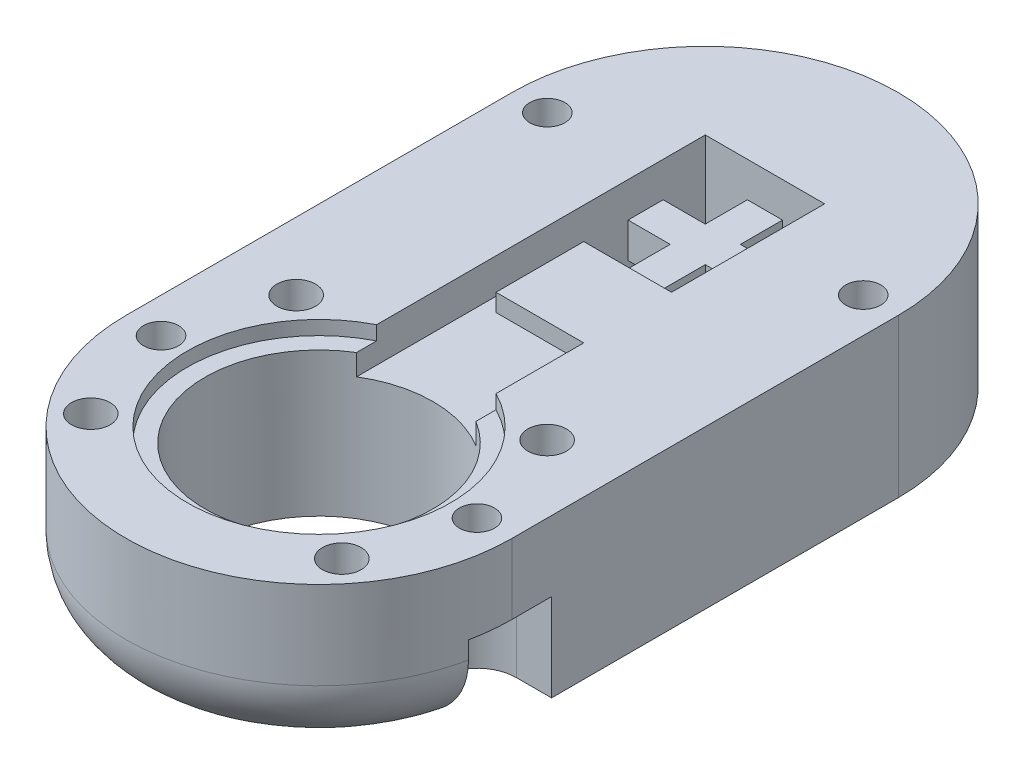
from build123d import *

# Parameters (mm, degrees)
SKETCH1_R           = 6.5
BOSS_EXTRUDE1_DEPTH = 9
SKETCH2_R           = 1.1
CUT_EXTRUDE1_DEPTH  = 3
SKETCH3_R           = 1
CUT_EXTRUDE2_DEPTH  = 20
CUT_EXTRUDE3_DEPTH  = 5
SKETCH6_W           = 6.8
SKETCH6_H           = 6.8
CUT_EXTRUDE4_DEPTH  = 5
SKETCH7_W           = 2.4
SKETCH7_H           = 2.4
CUT_EXTRUDE5_DEPTH  = 5
FILLET2_R           = 4
SKETCH8_R           = 1
CUT_EXTRUDE6_DEPTH  = 20
SKETCH9_R           = 7.5
CUT_EXTRUDE7_DEPTH  = 0.8
SKETCH10_W          = 6.8
SKETCH10_H          = 19.870144406
CUT_EXTRUDE8_DEPTH  = 2
SKETCH11_W          = 5
SKETCH11_H          = 1
BOSS_EXTRUDE2_DEPTH = 5


with BuildPart() as part:
    # Sketch1 → Boss-Extrude1 (new body)
    with BuildSketch(Plane(origin=(0, 0, 0), x_dir=(1, 0, 0), z_dir=(0, 1, 0))):
        with BuildLine():
            Line((-11, 0), (-11, 22.01))
            ThreePointArc((-11, 22.01), (-7.781103525, 29.781103525), (-0.01, 33))
            Line((-0.01, 33), (0.01, 33))
            ThreePointArc((0.01, 33), (7.781103525, 29.781103525), (11, 22.01))
            Line((11, 22.01), (11, 0))
            ThreePointArc((11, 0), (0, -11), (-11, 0))
        make_face()
        Circle(SKETCH1_R, mode=Mode.SUBTRACT)
    extrude(amount=BOSS_EXTRUDE1_DEPTH)

    # Sketch2 → Cut-Extrude1 (cut)
    with BuildSketch(Plane(origin=(0, 9, 0), x_dir=(1, 0, 0), z_dir=(0, 1, 0))):
        with Locations((-7.15, 5.85)):
            Circle(SKETCH2_R)
        with Locations((-7.15, -5.85)):
            Circle(SKETCH2_R)
        with Locations((7.15, -5.85)):
            Circle(SKETCH2_R)
        with Locations((7.15, 5.85)):
            Circle(SKETCH2_R)
    extrude(amount=-CUT_EXTRUDE1_DEPTH, mode=Mode.SUBTRACT)

    # Sketch3 → Cut-Extrude2 (cut)
    with BuildSketch(Plane(origin=(0, 9, 0), x_dir=(1, 0, 0), z_dir=(0, 1, 0))):
        with Locations((-9, 0)):
            Circle(SKETCH3_R)
        with Locations((9, 0)):
            Circle(SKETCH3_R)
    extrude(amount=-CUT_EXTRUDE2_DEPTH, mode=Mode.SUBTRACT)

    # Sketch4 → Cut-Extrude3 (cut)
    with BuildSketch(Plane.XZ):
        with BuildLine():
            Line((-9, 2.25), (-10.767427734, 2.25))
            Line((-10.767427734, 2.25), (-12, 0))
            Line((-12, 0), (-11, -2.25))
            Line((-11, -2.25), (-9, -2.25))
            ThreePointArc((-9, -2.25), (-6.75, 0), (-9, 2.25))
        make_face()
        with BuildLine():
            Line((12, 0), (10.767427734, 2.25))
            Line((10.767427734, 2.25), (9, 2.25))
            ThreePointArc((9, 2.25), (6.75, 0), (9, -2.25))
            Line((9, -2.25), (11, -2.25))
            Line((11, -2.25), (12, 0))
        make_face()
    extrude(amount=-CUT_EXTRUDE3_DEPTH, mode=Mode.SUBTRACT)

    # Sketch6 → Cut-Extrude4 (cut)
    with BuildSketch(Plane.XZ):
        with Locations((0, -22.01)):
            Rectangle(SKETCH6_W, SKETCH6_H)
    extrude(amount=-CUT_EXTRUDE4_DEPTH, mode=Mode.SUBTRACT)

    # Sketch7 → Cut-Extrude5 (cut)
    with BuildSketch(Plane.XZ.offset(-5)):
        with Locations((2.2, -19.81)):
            Rectangle(SKETCH7_W, SKETCH7_H)
        with Locations((-2.2, -19.81)):
            Rectangle(SKETCH7_W, SKETCH7_H)
        with Locations((2.2, -24.21)):
            Rectangle(SKETCH7_W, SKETCH7_H)
        with Locations((-2.2, -24.21)):
            Rectangle(SKETCH7_W, SKETCH7_H)
    extrude(amount=-CUT_EXTRUDE5_DEPTH, mode=Mode.SUBTRACT)

    # Fillet2
    fillet2_edges = [part.edges().sort_by_distance(p)[0] for p in [
        (0, 0, 11),
    ]]
    fillet(fillet2_edges, radius=FILLET2_R)

    # Sketch8 → Cut-Extrude6 (cut)
    with BuildSketch(Plane.XZ):
        with Locations((-9, -22.01)):
            Circle(SKETCH8_R)
        with Locations((9, -22.01)):
            Circle(SKETCH8_R)
    extrude(amount=-CUT_EXTRUDE6_DEPTH, mode=Mode.SUBTRACT)

    # Sketch9 → Cut-Extrude7 (cut)
    with BuildSketch(Plane(origin=(0, 9, 0), x_dir=(1, 0, 0), z_dir=(0, 1, 0))):
        Circle(SKETCH9_R)
    extrude(amount=-CUT_EXTRUDE7_DEPTH, mode=Mode.SUBTRACT)

    # Sketch10 → Cut-Extrude8 (cut)
    with BuildSketch(Plane(origin=(0, 9, 0), x_dir=(1, 0, 0), z_dir=(0, 1, 0))):
        with Locations((0, 15.474927797)):
            Rectangle(SKETCH10_W, SKETCH10_H)
    extrude(amount=-CUT_EXTRUDE8_DEPTH, mode=Mode.SUBTRACT)

    # Sketch11 → Boss-Extrude2 (add)
    with BuildSketch(Plane.ZY.offset(-3.4)):
        with Locations((-14.185057965, 8.5)):
            Rectangle(SKETCH11_W, SKETCH11_H)
    extrude(amount=BOSS_EXTRUDE2_DEPTH)


solid = part.part
